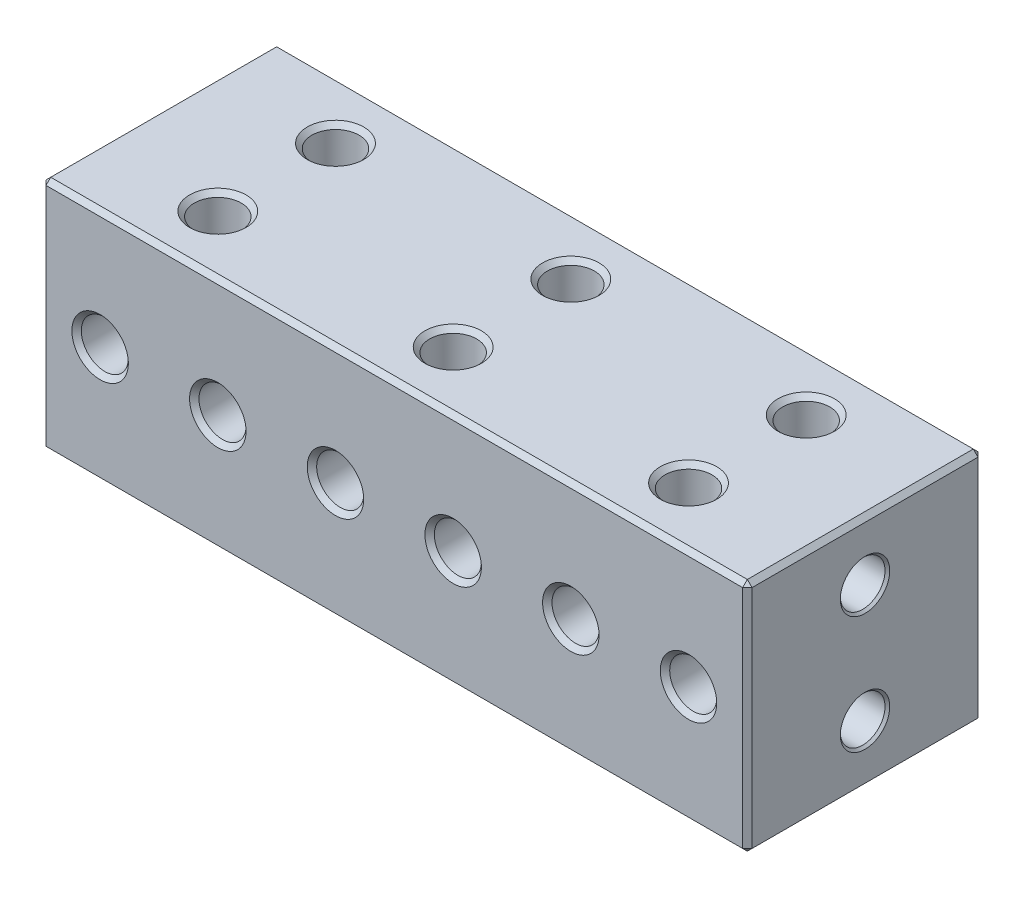
from build123d import *

# Parameters (mm, degrees)
SKETCH1_W                  = 10
SKETCH1_H                  = 10
BOSS_EXTRUDE1_DEPTH        = 15
SKETCH2_R                  = 1
CUT_EXTRUDE1_DEPTH         = 6
SKETCH3_R                  = 1
CUT_EXTRUDE2_DEPTH         = 6
CHAMFER1_SIZE              = 0.2
LPATTERN2_COUNT            = 3
LPATTERN2_PITCH            = 10
CHAMFER1_OF_LPATTERN2_SIZE = 0.2
SKETCH4_R                  = 0.95
CUT_EXTRUDE3_DEPTH         = 7
CHAMFER2_SIZE              = 0.2
CHAMFER3_SIZE              = 0.1


with BuildPart() as part:
    # Sketch1 → Boss-Extrude1 (new body, symmetric)
    with BuildSketch(Plane(origin=(0, 0, 0), x_dir=(0, 0, -1), z_dir=(1, 0, 0))):
        Rectangle(SKETCH1_W, SKETCH1_H)
    extrude(amount=BOSS_EXTRUDE1_DEPTH, both=True)

    # Sketch2 → Cut-Extrude1 (cut, symmetric)
    with BuildSketch(Plane.XY):
        with Locations((-12.5, 0)):
            Circle(SKETCH2_R)
        with Locations((-7.5, 0)):
            Circle(SKETCH2_R)
    cut_extrude1 = extrude(amount=CUT_EXTRUDE1_DEPTH, both=True, mode=Mode.SUBTRACT)

    # Sketch3 → Cut-Extrude2 (cut, symmetric)
    with BuildSketch(Plane(origin=(0, 0, 0), x_dir=(1, 0, 0), z_dir=(0, 1, 0))):
        with Locations(Location((-10, 2.5, 0), (0, 0, 270))):  # turned: the seam where the file's is
            Circle(SKETCH3_R)
        with Locations(Location((-10, -2.5, 0), (0, 0, 270))):  # turned: the seam where the file's is
            Circle(SKETCH3_R)
    cut_extrude2 = extrude(amount=CUT_EXTRUDE2_DEPTH, both=True, mode=Mode.SUBTRACT)

    # Chamfer1
    chamfer1_edges = [part.edges().sort_by_distance(p)[0] for p in [
        (-13.5, 0, -5),
        (-13.5, 0, 5),
        (-8.5, 0, -5),
        (-8.5, 0, 5),
        (-10, -5, -3.5),
        (-10, 5, -3.5),
        (-10, -5, 1.5),
        (-10, 5, 1.5),
    ]]
    chamfer(chamfer1_edges, length=CHAMFER1_SIZE)

    # LPattern2: Cut-Extrude1, Cut-Extrude2 ×3
    with Locations(*[(i * LPATTERN2_PITCH, 0, 0) for i in range(1, LPATTERN2_COUNT)]):
        add(cut_extrude1, mode=Mode.SUBTRACT)
        add(cut_extrude2, mode=Mode.SUBTRACT)

    # Chamfer1 of LPattern2
    chamfer1_of_lpattern2_edges = [part.edges().sort_by_distance(p)[0] for p in [
        (-3.5, 0, -5),
        (-3.5, 0, 5),
        (1.5, 0, -5),
        (1.5, 0, 5),
        (0, -5, -3.5),
        (0, 5, -3.5),
        (0, -5, 1.5),
        (0, 5, 1.5),
        (6.5, 0, -5),
        (6.5, 0, 5),
        (11.5, 0, -5),
        (11.5, 0, 5),
        (10, -5, -3.5),
        (10, 5, -3.5),
        (10, -5, 1.5),
        (10, 5, 1.5),
    ]]
    chamfer(chamfer1_of_lpattern2_edges, length=CHAMFER1_OF_LPATTERN2_SIZE)

    # Sketch4 → Cut-Extrude3 (cut)
    with BuildSketch(Plane.ZY.offset(15)):
        with Locations((0, 2.5)):
            Circle(SKETCH4_R)
        with Locations((0, -2.5)):
            Circle(SKETCH4_R)
    cut_extrude3 = extrude(amount=-CUT_EXTRUDE3_DEPTH, mode=Mode.SUBTRACT)

    # Mirror1: Cut-Extrude3 across plane
    add(cut_extrude3.mirror(Plane(origin=(0, 0, 0), x_dir=(0, 0, 1), z_dir=(1, 0, 0))), mode=Mode.SUBTRACT)

    # Chamfer2
    chamfer2_edges = [part.edges().sort_by_distance(p)[0] for p in [
        (15, 0, -5),
        (15, 5, 0),
        (15, 0, 5),
        (-15, 5, 0),
        (-15, 0, -5),
        (-15, -5, 0),
        (-15, 0, 5),
        (15, -5, 0),
        (0, 5, 5),
        (0, 5, -5),
        (0, -5, -5),
        (0, -5, 5),
    ]]
    chamfer(chamfer2_edges, length=CHAMFER2_SIZE)

    # Chamfer3
    chamfer3_edges = [part.edges().sort_by_distance(p)[0] for p in [
        (-15, 2.5, -0.95),
        (-15, -2.5, -0.95),
        (15, 2.5, -0.95),
        (15, -2.5, -0.95),
    ]]
    chamfer(chamfer3_edges, length=CHAMFER3_SIZE)


solid = part.part
